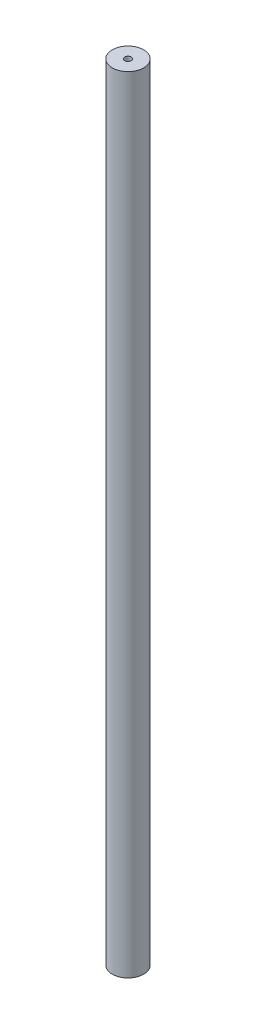
from build123d import *

# Parameters (mm, degrees)
SKETCH1_R                                         = 5
BOSS_EXTRUDE1_DEPTH                               = 250
CSK_FOR_1_FLAT_HEAD_SOCKET_CAP_SCREW1_D           = 2.0574
CSK_FOR_1_FLAT_HEAD_SOCKET_CAP_SCREW1_CSINK_D     = 4.2672
CSK_FOR_1_FLAT_HEAD_SOCKET_CAP_SCREW1_CSINK_ANGLE = 82


with BuildPart() as part:
    # Sketch1 → Boss-Extrude1 (new body)
    with BuildSketch(Plane(origin=(0, 0, 0), x_dir=(1, 0, 0), z_dir=(0, 1, 0))):
        Circle(SKETCH1_R)
    extrude(amount=BOSS_EXTRUDE1_DEPTH)

    # CSK for #1 Flat Head Socket Cap Screw1 (through all)
    with Locations(Plane(origin=(0, 0, 0), x_dir=(-1, 0, 0), z_dir=(0, -1, 0))):
        with Locations((0, 0)):
            CounterSinkHole(CSK_FOR_1_FLAT_HEAD_SOCKET_CAP_SCREW1_D / 2, CSK_FOR_1_FLAT_HEAD_SOCKET_CAP_SCREW1_CSINK_D / 2, counter_sink_angle=CSK_FOR_1_FLAT_HEAD_SOCKET_CAP_SCREW1_CSINK_ANGLE)


solid = part.part
